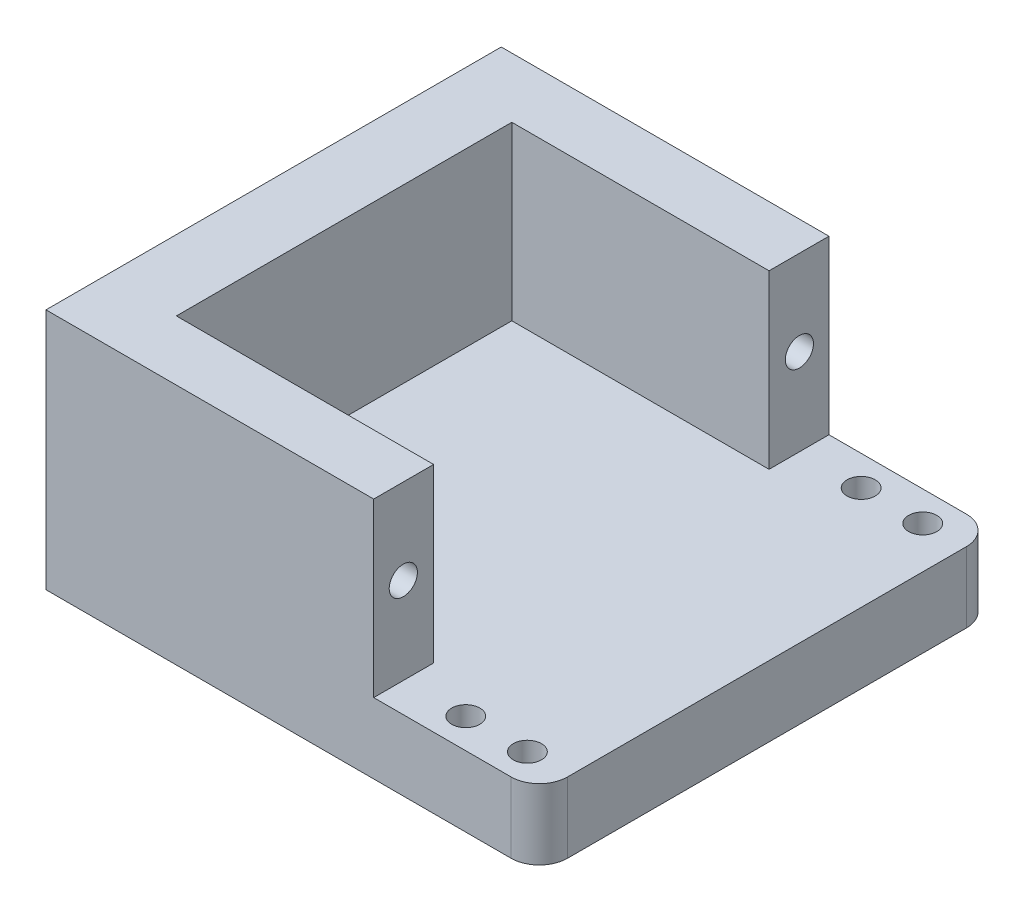
from build123d import *

# Parameters (mm, degrees)
SKETCH4_W           = 35
SKETCH4_H           = 32.3
BOSS_EXTRUDE3_DEPTH = 5
SKETCH6_W           = 5
SKETCH6_H           = 32.3
BOSS_EXTRUDE5_DEPTH = 12.2
SKETCH8_W           = 18.25
SKETCH8_H           = 4.25
BOSS_EXTRUDE6_DEPTH = 12.2
SKETCH10_R          = 1
CUT_EXTRUDE1_DEPTH  = 5
SKETCH11_R          = 1
CUT_EXTRUDE2_DEPTH  = 5
SKETCH12_R          = 1
CUT_EXTRUDE3_DEPTH  = 5
FILLET2_R           = 2


with BuildPart() as part:
    # Sketch4 → Boss-Extrude3 (new body)
    with BuildSketch(Plane(origin=(0, 0, 0), x_dir=(1, 0, 0), z_dir=(0, 1, 0))):
        with Locations((17.5, 16.15)):
            Rectangle(SKETCH4_W, SKETCH4_H)
    extrude(amount=BOSS_EXTRUDE3_DEPTH)

    # Sketch6 → Boss-Extrude5 (add)
    with BuildSketch(Plane(origin=(0, 5, 0), x_dir=(1, 0, 0), z_dir=(0, 1, 0))):
        with Locations((2.5, 16.15)):
            Rectangle(SKETCH6_W, SKETCH6_H)
    extrude(amount=BOSS_EXTRUDE5_DEPTH)

    # Sketch8 → Boss-Extrude6 (add)
    with BuildSketch(Plane(origin=(0, 5, 0), x_dir=(1, 0, 0), z_dir=(0, 1, 0))):
        with Locations((14.125, 2.125)):
            Rectangle(SKETCH8_W, SKETCH8_H)
        with Locations((14.125, 30.175)):
            Rectangle(SKETCH8_W, SKETCH8_H)
    extrude(amount=BOSS_EXTRUDE6_DEPTH)

    # Sketch10 → Cut-Extrude1 (cut)
    with BuildSketch(Plane(origin=(23.25, 0, 0), x_dir=(0, 0, -1), z_dir=(1, 0, 0))):
        with Locations((2.1, 11.15)):
            Circle(SKETCH10_R)
        with Locations((30.2, 11.15)):
            Circle(SKETCH10_R)
    extrude(amount=-CUT_EXTRUDE1_DEPTH, mode=Mode.SUBTRACT)

    # Sketch11 → Cut-Extrude2 (cut)
    with BuildSketch(Plane(origin=(0, 5, 0), x_dir=(1, 0, 0), z_dir=(0, 1, 0))):
        with BuildLine():
            ThreePointArc((28.65708215, 30.175), (27.65708215, 31.175), (26.65708215, 30.175))
            Line((26.65708215, 30.175), (28.65708215, 30.175))
        make_face()
        with BuildLine():
            Line((28.65708215, 30.175), (26.65708215, 30.175))
            ThreePointArc((26.65708215, 30.175), (27.65708215, 29.175), (28.65708215, 30.175))
        make_face()
        with BuildLine():
            ThreePointArc((33.028108072, 30.175), (32.028108072, 31.175), (31.028108072, 30.175))
            Line((31.028108072, 30.175), (33.028108072, 30.175))
        make_face()
        with BuildLine():
            Line((33.028108072, 30.175), (31.028108072, 30.175))
            ThreePointArc((31.028108072, 30.175), (32.028108072, 29.175), (33.028108072, 30.175))
        make_face()
        with Locations((27.65708215, 2.125)):
            Circle(SKETCH11_R)
        with Locations((32.028108072, 2.125)):
            Circle(SKETCH11_R)
    extrude(amount=-CUT_EXTRUDE2_DEPTH, mode=Mode.SUBTRACT)

    # Sketch12 → Cut-Extrude3 (cut)
    with BuildSketch(Plane.XZ):
        with Locations((2.322349093, -2.125)):
            Circle(SKETCH12_R)
        with Locations((2.322349093, -30.175)):
            Circle(SKETCH12_R)
    extrude(amount=-CUT_EXTRUDE3_DEPTH, mode=Mode.SUBTRACT)

    # Fillet2
    fillet2_edges = [part.edges().sort_by_distance(p)[0] for p in [
        (35, 2.5, -32.3),
        (35, 2.5, 0),
    ]]
    fillet(fillet2_edges, radius=FILLET2_R)


solid = part.part
